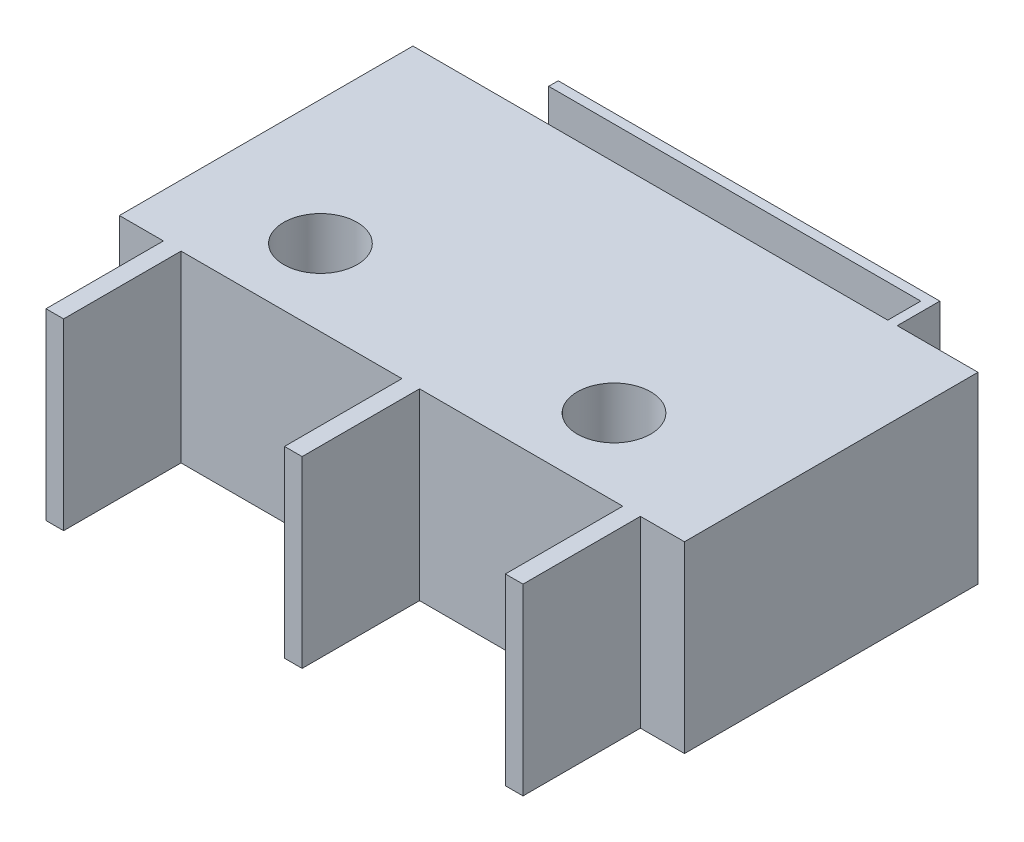
from build123d import *

# Parameters (mm, degrees)
SKETCH1_W           = 19.558
SKETCH1_H           = 10.16
SKETCH1_W_2         = 0.6096
SKETCH1_H_2         = 4.064
BOSS_EXTRUDE1_DEPTH = 6.35
SKETCH2_R           = 1.27
CUT_EXTRUDE1_DEPTH  = 6.35
SKETCH1_4_W         = 0.3302
SKETCH1_4_H         = 1.143
BOSS_EXTRUDE2_DEPTH = 6.35


with BuildPart() as part:
    # Sketch1 → Boss-Extrude1 (new body)
    with BuildSketch(Plane(origin=(0, 0, 0), x_dir=(1, 0, 0), z_dir=(0, 1, 0))):
        with Locations((10.092764077, 6.29705611)):
            Rectangle(SKETCH1_W, SKETCH1_H)
        with Locations((2.142564077, -0.81494389)):
            Rectangle(SKETCH1_W_2, SKETCH1_H_2)
        with Locations((18.042964077, -0.81494389)):
            Rectangle(SKETCH1_W_2, SKETCH1_H_2)
        with Locations((10.397564077, -0.81494389)):
            Rectangle(SKETCH1_W_2, SKETCH1_H_2)
    extrude(amount=BOSS_EXTRUDE1_DEPTH)

    # Sketch2 → Cut-Extrude1 (cut)
    with BuildSketch(Plane(origin=(0, 6.35, 0), x_dir=(1, 0, 0), z_dir=(0, 1, 0))):
        with Locations((4.631764077, 3.858413602)):
            Circle(SKETCH2_R)
        with Locations((14.791764077, 3.858413602)):
            Circle(SKETCH2_R)
    extrude(amount=-CUT_EXTRUDE1_DEPTH, mode=Mode.SUBTRACT)

    # Sketch1_4 → Boss-Extrude2 (add)
    with BuildSketch(Plane(origin=(0, 0, 0), x_dir=(1, 0, 0), z_dir=(0, 1, 0))):
        with Locations((16.912664077, 11.94855611)):
            Rectangle(SKETCH1_4_W, SKETCH1_4_H)
        Polygon((16.747564077, 12.52005611), (17.077764077, 12.52005611), (17.077764077, 12.85025611), (3.869764077, 12.85025611), (3.869764077, 12.52005611), align=None)
    extrude(amount=BOSS_EXTRUDE2_DEPTH)


solid = part.part
